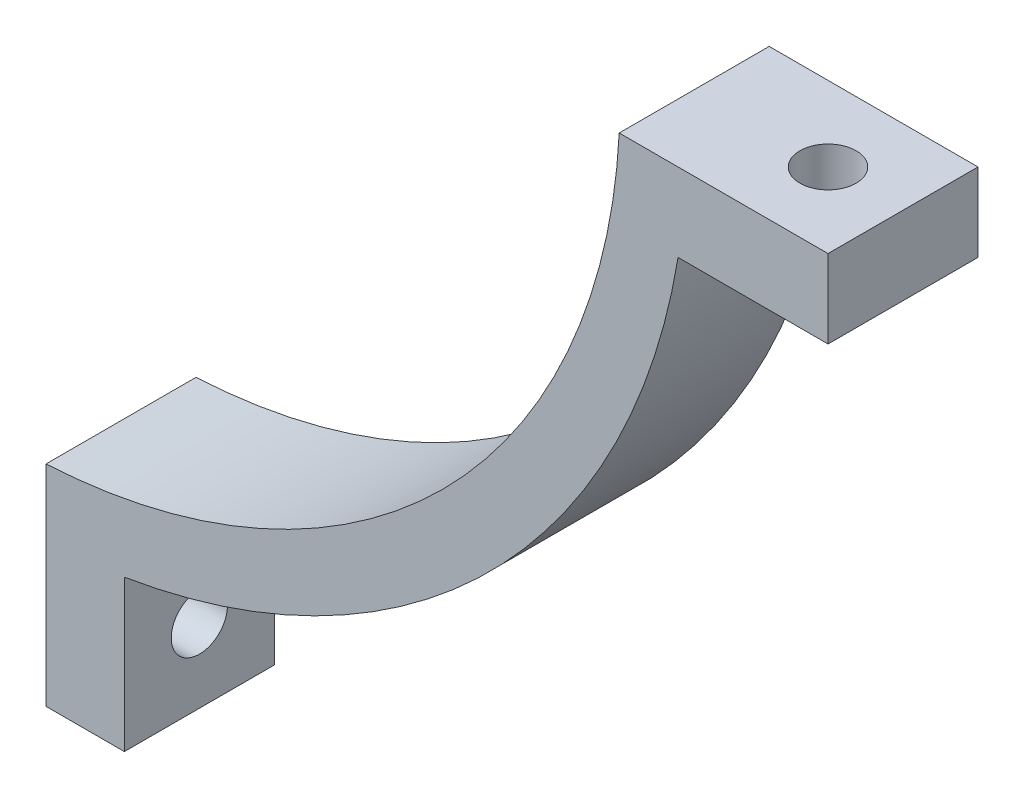
from build123d import *

# Parameters (mm, degrees)
BOSS_EXTRUDE3_DEPTH = 12.7
SKETCH2_R           = 2.38125
CUT_EXTRUDE1_DEPTH  = 7.63575
SKETCH3_R           = 2.38125
CUT_EXTRUDE2_DEPTH  = 7.63575


with BuildPart() as part:
    # Sketch1 → Boss-Extrude3 (new body)
    with BuildSketch(Plane.XY):
        with BuildLine():
            Line((51.176153738, -2.63525), (68.859545977, -2.63525))
            Line((68.859545977, -2.63525), (68.859545977, -9.271))
            Line((68.859545977, -9.271), (56.159545977, -9.271))
            ThreePointArc((56.159545977, -9.271), (40.248267325, -40.248267325), (9.271, -56.159545977))
            Line((9.271, -56.159545977), (9.271, -68.956153738))
            Line((9.271, -68.956153738), (2.63525, -68.956153738))
            Line((2.63525, -68.956153738), (2.63525, -51.176153738))
            ThreePointArc((2.63525, -51.176153738), (36.234950351, -36.234950351), (51.176153738, -2.63525))
        make_face()
    extrude(amount=BOSS_EXTRUDE3_DEPTH)

    # Sketch2 → Cut-Extrude1 (cut, through all)
    with BuildSketch(Plane(origin=(9.271, 0, 0), x_dir=(0, 0, -1), z_dir=(1, 0, 0))):
        with Locations((-6.35, -62.606153738)):
            Circle(SKETCH2_R)
    extrude(amount=-CUT_EXTRUDE1_DEPTH, mode=Mode.SUBTRACT)

    # Sketch3 → Cut-Extrude2 (cut, through all)
    with BuildSketch(Plane.XZ.offset(9.271)):
        with Locations((62.509545977, 6.35)):
            Circle(SKETCH3_R)
    extrude(amount=-CUT_EXTRUDE2_DEPTH, mode=Mode.SUBTRACT)


solid = part.part
